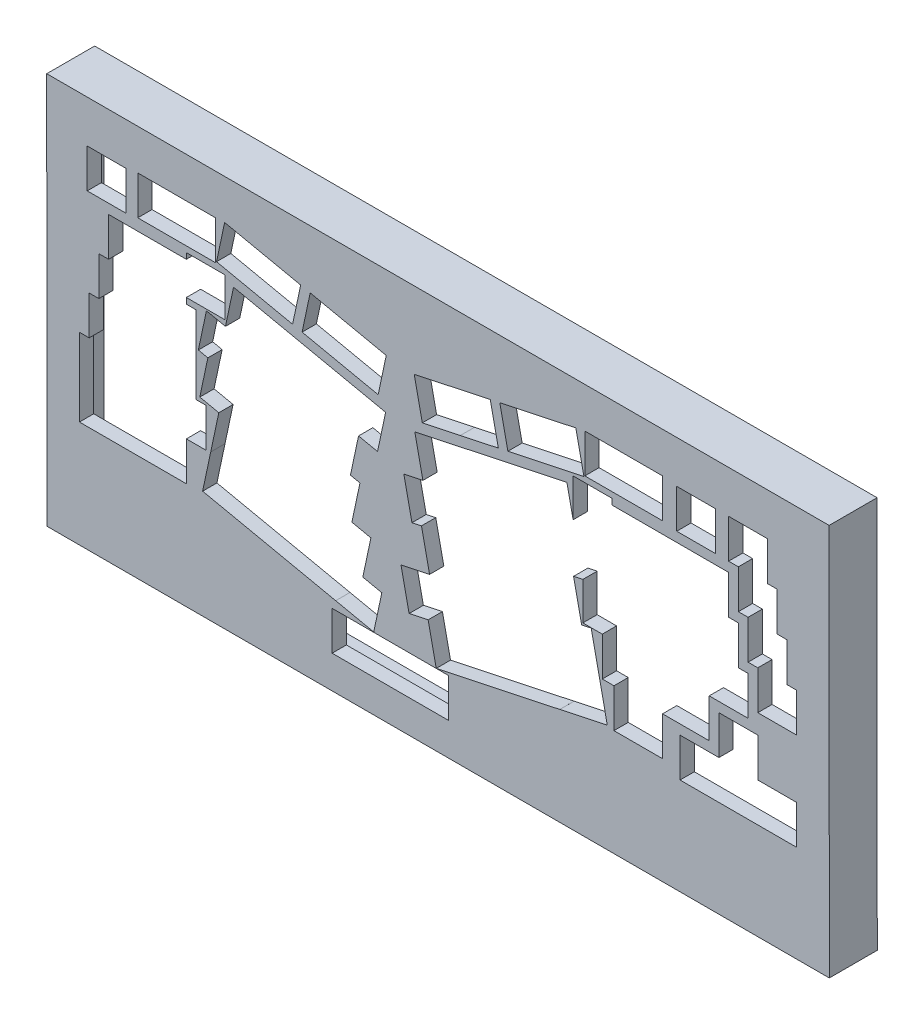
from build123d import *

# Parameters (mm, degrees)
MODEL_W             = 57.154
MODEL_H             = 19.05137
MODEL_W_2           = 19.051
MODEL_H_2           = 19.051
MODEL_W_3           = 19.0514
MODEL_W_4           = 38.103
MODEL_W_5           = 38.1028
EXTRUDE_1_DEPTH     = 23.5
SKETCH_2_W          = 368.48
SKETCH_2_H          = 177.02
CUT_EXTRUDE_1_DEPTH = 16.5
CUT_EXTRUDE_2_DEPTH = 3


with BuildPart() as part:
    # Model → 凸台-拉伸1 (new body)
    with BuildSketch(Plane.XY):
        Polygon((-7.904930268, -7.726795577), (-7.935386074, 184.294), (375.473711158, 184.294), (375.566, -7.74368854), align=None)
        with Locations((160.494, 17.799415)):
            Rectangle(MODEL_W, MODEL_H, mode=Mode.SUBTRACT)
        Polygon((250.028, 142.579), (250.028, 123.963), (246.976, 138.322), (228.342, 134.36), (209.708, 130.4), (209.708, 130.401), (172.44, 122.479), (176.4, 103.845), (167.083, 101.865), (171.045, 83.228), (175.703, 84.2186), (179.663, 65.5863), (165.687, 62.6166), (169.649, 43.9801), (178.966, 45.9617), (182.926, 27.3279), (243.487, 40.2001), (243.487, 40.1987), (266.78, 45.1513), (258.859, 82.4205), (254.2, 81.431), (250.241, 100.062), (254.791, 101.03), (254.791, 82.568), (264.316, 82.568), (264.316, 63.518), (270.031, 63.518), (270.031, 44.468), (293.846, 44.468), (293.846, 63.518), (316.705, 63.518), (316.705, 82.568), (335.755, 82.568), (335.755, 101.621), (330.992, 101.621), (330.992, 120.671), (326.23, 120.671), (326.23, 139.721), (269.08, 139.721), (269.08, 142.579), align=None, mode=Mode.SUBTRACT)
        Polygon((79.6452, 120.831), (70.327, 122.811), (66.3663, 104.176), (71.0255, 103.185), (67.0648, 84.551), (76.382, 82.5722), (72.42, 63.9367), (72.4214, 63.9367), (68.4597, 45.303), (133.679, 31.4399), (133.679, 31.4413), (152.313, 27.4808), (156.275, 46.1162), (146.958, 48.0949), (150.919, 66.7286), (141.602, 68.7091), (145.562, 87.3428), (140.903, 88.3338), (144.865, 106.966), (154.182, 104.986), (158.142, 123.621), (139.507, 127.583), (139.507, 127.581), (83.6055, 139.464), align=None, mode=Mode.SUBTRACT)
        Polygon((321.466, 77.8083), (321.466, 58.7583), (302.416, 58.7583), (302.416, 39.7069), (359.569, 39.7069), (359.569, 58.7583), (340.517, 58.7583), (340.517, 77.8083), align=None, mode=Mode.SUBTRACT)
        Polygon((60.4795, 142.579), (60.4795, 139.721), (22.3807, 139.721), (22.3807, 120.671), (17.6182, 120.671), (17.6182, 101.621), (12.8557, 101.621), (12.8557, 82.5708), (8.09322, 82.5708), (8.09322, 44.468), (60.482, 44.468), (60.482, 63.518), (70.007, 63.518), (70.007, 82.5708), (65.2459, 82.5708), (65.2459, 120.671), (60.482, 120.671), (60.482, 123.526), (79.532, 123.526), (79.532, 142.579), align=None, mode=Mode.SUBTRACT)
        Polygon((326.227, 163.533), (326.227, 144.482), (330.991, 144.482), (330.991, 125.432), (335.753, 125.432), (335.753, 106.382), (340.516, 106.382), (340.516, 87.3319), (359.569, 87.3319), (359.569, 106.383), (354.806, 106.383), (354.806, 125.433), (350.042, 125.433), (350.042, 144.483), (345.28, 144.483), (345.28, 163.533), align=None, mode=Mode.SUBTRACT)
        Polygon((172.146, 146.761), (176.109, 128.126), (194.741, 132.086), (194.741, 132.085), (213.377, 136.047), (209.416, 154.682), align=None, mode=Mode.SUBTRACT)
        Polygon((117.205, 137.189), (154.474, 129.267), (158.434, 147.903), (121.165, 155.826), align=None, mode=Mode.SUBTRACT)
        Polygon((214.073, 155.673), (218.033, 137.036), (255.304, 144.959), (251.343, 163.594), align=None, mode=Mode.SUBTRACT)
        Polygon((75.2782, 146.101), (112.547, 138.18), (116.509, 156.815), (97.874, 160.776), (79.2399, 164.736), align=None, mode=Mode.SUBTRACT)
        with Locations((310.3225, 154.0075)):
            Rectangle(MODEL_W_2, MODEL_H_2, mode=Mode.SUBTRACT)
        with Locations((21.4292, 154.0075)):
            Rectangle(MODEL_W_3, MODEL_H_2, mode=Mode.SUBTRACT)
        with Locations((274.7945, 154.9595)):
            Rectangle(MODEL_W_4, MODEL_H_2, mode=Mode.SUBTRACT)
        with Locations((55.7195, 154.9595)):
            Rectangle(MODEL_W_5, MODEL_H_2, mode=Mode.SUBTRACT)
    extrude(amount=EXTRUDE_1_DEPTH)

    # 草图2 → 切除-拉伸1 (cut)
    with BuildSketch(Plane(origin=(0, 0, 0), x_dir=(-1, 0, 0), z_dir=(0, 0, -1))):
        with Locations((-183.826556737, 88.283426)):
            Rectangle(SKETCH_2_W, SKETCH_2_H)
    extrude(amount=-CUT_EXTRUDE_1_DEPTH, mode=Mode.SUBTRACT)

    # 草图3 → 切除-拉伸2 (cut)
    with BuildSketch(Plane(origin=(0, 0, 0), x_dir=(-1, 0, 0), z_dir=(0, 0, -1))):
        Polygon((-374.06527893, -6.243622428), (6.405168149, -6.226861644), (6.435148145, 182.794), (-373.97443185, 182.794), align=None)
    extrude(amount=-CUT_EXTRUDE_2_DEPTH, mode=Mode.SUBTRACT)


solid = part.part
